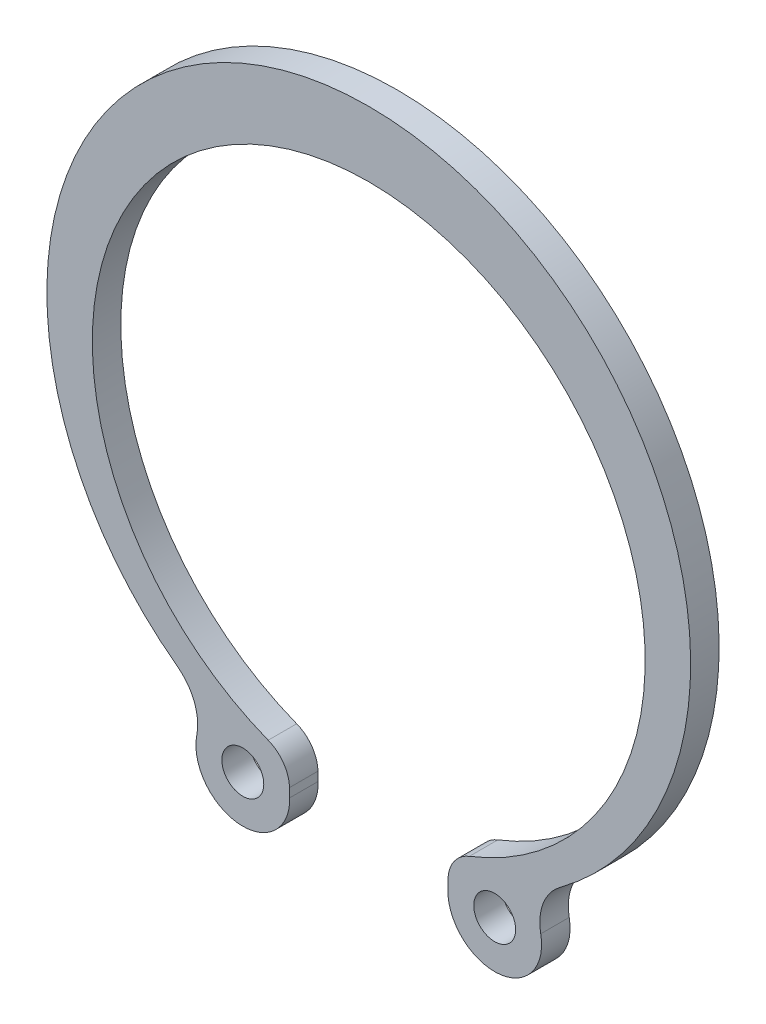
from build123d import *

# Parameters (mm, degrees)
SKETCH_2_R      = 1.25
EXTRUDE_1_DEPTH = 1.7


with BuildPart() as part:
    # Эскиз2 → Бобышка-Вытянуть1 (new body)
    with BuildSketch(Plane.XY):
        with BuildLine():
            Line((0, 16.5), (0, 20.4))
            ThreePointArc((0, 20.4), (-18.247161486, 7.202535297), (-11.42657443, -14.259327835))
            ThreePointArc((-11.42657443, -14.259327835), (-10.414964854, -15.583182123), (-10.265681334, -17.242597243))
            ThreePointArc((-10.265681334, -17.242597243), (-7.750266266, -20.566241003), (-4.717815883, -17.706491802))
            Line((-4.717815883, -17.706491802), (-4.730782246, -17.182866897))
            ThreePointArc((-4.730782246, -17.182866897), (-5.092718531, -16.084006582), (-6.002583463, -15.369417418))
            ThreePointArc((-6.002583463, -15.369417418), (-16.21489111, 3.054063899), (0, 16.5))
        make_face()
        with Locations((-7.516953538, -17.77597844)):
            Circle(SKETCH_2_R, mode=Mode.SUBTRACT)
    extrude(amount=EXTRUDE_1_DEPTH)

    # Зеркальное отражение1: part across plane


with BuildPart() as part_1:
    add(part.part)
    add(part.part.mirror(Plane(origin=(0, 16.5, 1.7), x_dir=(0, 0, 1), z_dir=(-1, 0, 0))))


solid = part_1.part
